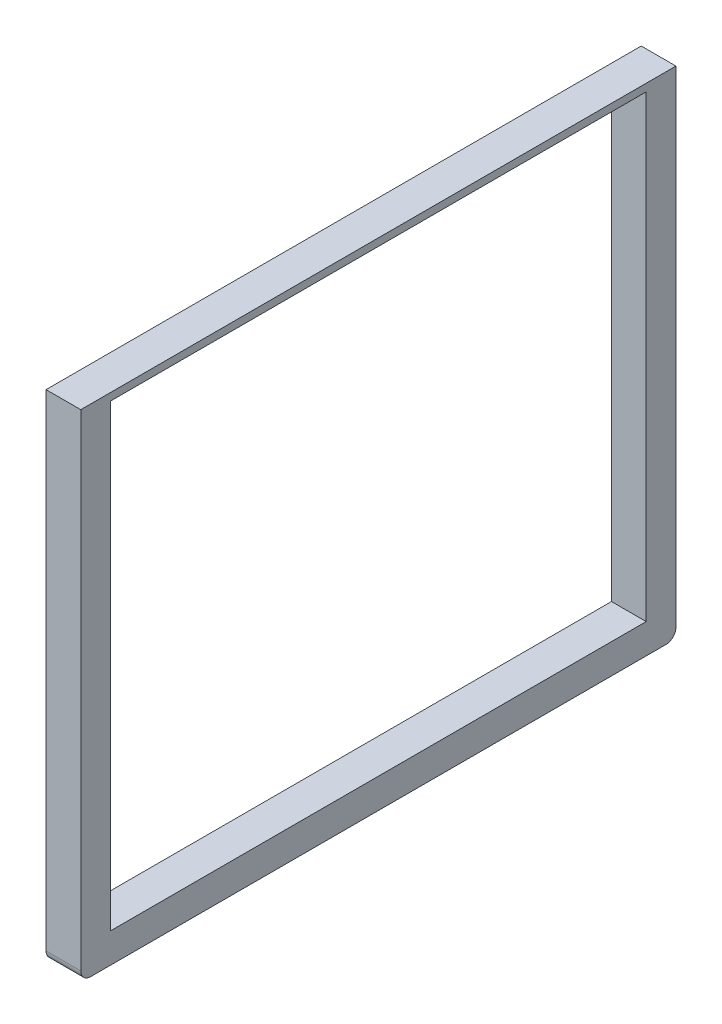
from build123d import *

# Parameters (mm, degrees)
BOSS_EXTRUDE1_DEPTH = 35
SKETCH2_W           = 539.999711362
SKETCH2_H           = 462.5
CUT_EXTRUDE1_DEPTH  = 35
FILLET1_R           = 10


with BuildPart() as part:
    # Sketch1 → Boss-Extrude1 (new body)
    with BuildSketch(Plane(origin=(0, 0, 0), x_dir=(0, 0, -1), z_dir=(1, 0, 0))):
        Polygon((-310.498220641, 250), (289.501486325, 250), (289.501779359, -250), (-310.498220641, -250), align=None)
    extrude(amount=BOSS_EXTRUDE1_DEPTH)

    # Sketch2 → Cut-Extrude1 (cut)
    with BuildSketch(Plane(origin=(35, 0, 0), x_dir=(0, 0, -1), z_dir=(1, 0, 0))):
        with Locations((-10.49836496, 11.25)):
            Rectangle(SKETCH2_W, SKETCH2_H)
    extrude(amount=-CUT_EXTRUDE1_DEPTH, mode=Mode.SUBTRACT)

    # Fillet1
    fillet1_edges = [part.edges().sort_by_distance(p)[0] for p in [
        (17.5, -250, -289.501779359),
        (17.5, -250, 310.498220641),
    ]]
    fillet(fillet1_edges, radius=FILLET1_R)


solid = part.part
